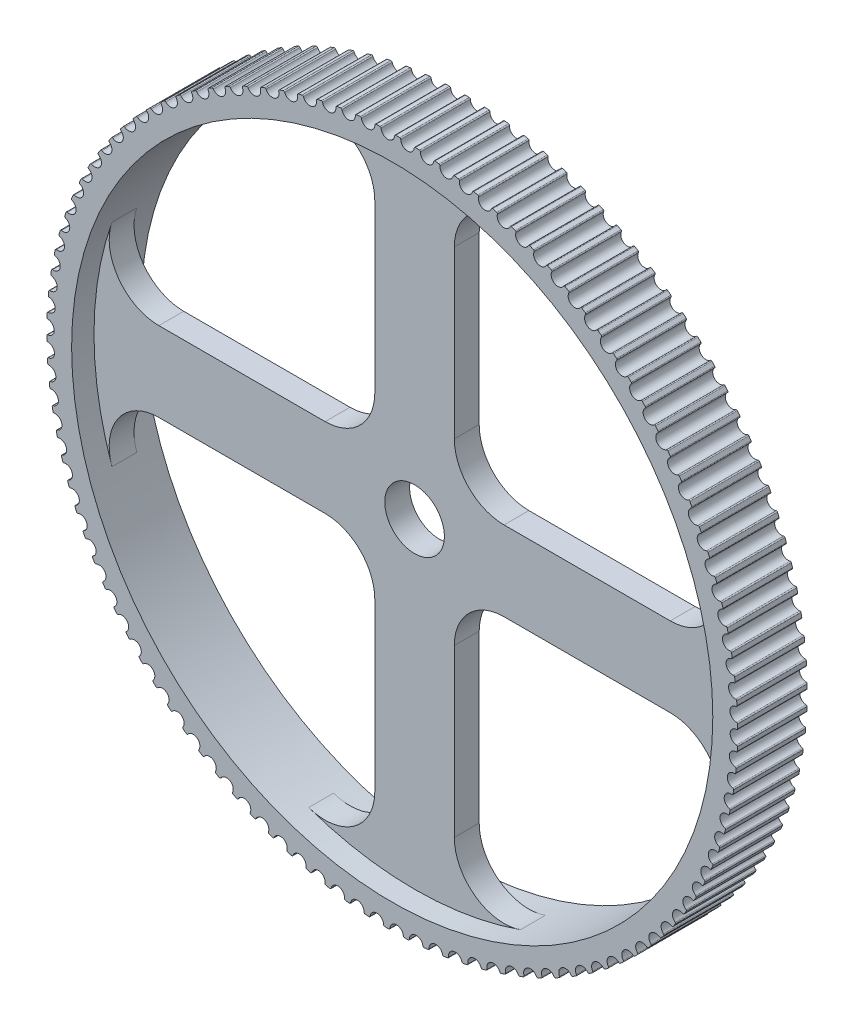
from build123d import *

# Parameters (mm, degrees)
BOSS_EXTRUDE1_DEPTH = 3.5
SKETCH4_R           = 32.25
CUT_EXTRUDE2_DEPTH  = 3.5
SKETCH6_R           = 3
BOSS_EXTRUDE2_DEPTH = 1.25
FILLET1_R           = 5
FILLET2_R           = 5


with BuildPart() as part:
    # Sketch2 → Boss-Extrude1 (new body, symmetric)
    with BuildSketch(Plane.XY):
        with BuildLine():
            ThreePointArc((-3.211333328, 34.601298216), (-3.132582306, 34.577768977), (-3.092122191, 34.506226488))
            ThreePointArc((-3.092122191, 34.506226488), (-2.370608918, 33.917255392), (-1.738041502, 34.600868455))
            ThreePointArc((-1.738041502, 34.600868455), (-1.707926922, 34.677343683), (-1.633214692, 34.711599067))
            ThreePointArc((-1.633214692, 34.711599067), (-1.432005901, 34.720481839), (-1.230749008, 34.728198296))
            ThreePointArc((-1.230749008, 34.728198296), (-1.153469677, 34.700211628), (-1.117159824, 34.626475997))
            ThreePointArc((-1.117159824, 34.626475997), (-0.430446923, 33.997275118), (0.240115498, 34.643660757))
            ThreePointArc((0.240115498, 34.643660757), (0.274546844, 34.718292057), (0.351092826, 34.748226341))
            ThreePointArc((0.351092826, 34.748226341), (0.552480572, 34.745607855), (0.75384976, 34.741822211))
            ThreePointArc((0.75384976, 34.741822211), (0.829405331, 34.709469401), (0.861446487, 34.63378114))
            ThreePointArc((0.861446487, 34.63378114), (1.5111191, 33.966402798), (2.217489291, 34.573452638))
            ThreePointArc((2.217489291, 34.573452638), (2.256125096, 34.645996578), (2.334255151, 34.671512123))
            ThreePointArc((2.334255151, 34.671512123), (2.535164969, 34.657400921), (2.735989626, 34.642125523))
            ThreePointArc((2.735989626, 34.642125523), (2.809574991, 34.6055121), (2.837242938, 34.528118086))
            ThreePointArc((2.837242938, 34.528118086), (3.447756167, 33.824739133), (4.187630095, 34.390473103))
            ThreePointArc((4.187630095, 34.390473103), (4.230344336, 34.460693059), (4.309803622, 34.481706639))
            ThreePointArc((4.309803622, 34.481706639), (4.509580184, 34.456148748), (4.709205264, 34.429433422))
            ThreePointArc((4.709205264, 34.429433422), (4.780580401, 34.388678811), (4.803784892, 34.309831489))
            ThreePointArc((4.803784892, 34.309831489), (5.373147369, 33.572746199), (6.14411172, 34.095318993))
            ThreePointArc((6.14411172, 34.095318993), (6.190765072, 34.162985922), (6.271294408, 34.179428995))
            ThreePointArc((6.271294408, 34.179428995), (6.469286087, 34.14250778), (6.667060452, 34.104439666))
            ThreePointArc((6.667060452, 34.104439666), (6.735992552, 34.059676799), (6.754657899, 33.979633352))
            ThreePointArc((6.754657899, 33.979633352), (7.281012482, 33.211245945), (8.080552529, 33.68895304))
            ThreePointArc((8.080552529, 33.68895304), (8.13099282, 33.753846226), (8.212329536, 33.765665158))
            ThreePointArc((8.212329536, 33.765665158), (8.407890523, 33.717501049), (8.603169075, 33.668204316))
            ThreePointArc((8.603169075, 33.668204316), (8.669433295, 33.619579201), (8.683498616, 33.538600714))
            ThreePointArc((8.683498616, 33.538600714), (9.165128446, 32.74141751), (9.990636256, 33.172700723))
            ThreePointArc((9.990636256, 33.172700723), (10.044698959, 33.2346085), (10.126577752, 33.24176474))
            ThreePointArc((10.126577752, 33.24176474), (10.319070167, 33.182514837), (10.511215949, 33.122150282))
            ThreePointArc((10.511215949, 33.122150282), (10.574596148, 33.069821524), (10.584015565, 32.988172132))
            ThreePointArc((10.584015565, 32.988172132), (11.019349666, 32.164793376), (11.868132604, 32.548245952))
            ThreePointArc((11.868132604, 32.548245952), (11.925641377, 32.606966388), (12.007795176, 32.609436594))
            ThreePointArc((12.007795176, 32.609436594), (12.196591149, 32.539294158), (12.384977421, 32.468058678))
            ThreePointArc((12.384977421, 32.468058678), (12.445266867, 32.412196962), (12.450009655, 32.330142989))
            ThreePointArc((12.450009655, 32.330142989), (12.837628057, 31.483254372), (13.70691757, 31.817625568))
            ThreePointArc((13.70691757, 31.817625568), (13.767684832, 31.87296713), (13.849845668, 31.870743245))
            ThreePointArc((13.849845668, 31.870743245), (14.034329387, 31.789937066), (14.21834167, 31.708063015))
            ThreePointArc((14.21834167, 31.708063015), (14.275343712, 31.648850551), (14.275394401, 31.566659639))
            ThreePointArc((14.275394401, 31.566659639), (14.614032774, 30.699023536), (15.50099342, 30.983222703))
            ThreePointArc((15.50099342, 30.983222703), (15.564820961, 31.035004878), (15.646720842, 31.028094155))
            ThreePointArc((15.646720842, 31.028094155), (15.826290558, 30.936887807), (16.005328645, 30.844642241))
            ThreePointArc((16.005328645, 30.844642241), (16.058857353, 30.782272168), (16.054215778, 30.700212407))
            ThreePointArc((16.054215778, 30.700212407), (16.342769554, 29.814658866), (17.244508252, 30.047759005))
            ThreePointArc((17.244508252, 30.047759005), (17.31118788, 30.09581289), (17.392559666, 30.084237871))
            ThreePointArc((17.392559666, 30.084237871), (17.56662966, 29.982928849), (17.740109564, 29.880612655))
            ThreePointArc((17.740109564, 29.880612655), (17.78999034, 29.815288411), (17.78067164, 29.733627463))
            ThreePointArc((17.78067164, 29.733627463), (18.018199616, 28.833044976), (18.931775082, 29.014285763))
            ThreePointArc((18.931775082, 29.014285763), (19.001089301, 29.058454616), (19.081667574, 29.042253056))
            ThreePointArc((19.081667574, 29.042253056), (19.249670067, 28.93117181), (19.417025934, 28.819118722))
            ThreePointArc((19.417025934, 28.819118722), (19.463096075, 28.75105338), (19.449130647, 28.670057606))
            ThreePointArc((19.449130647, 28.670057606), (19.634858056, 27.757383686), (20.557290396, 27.886173951))
            ThreePointArc((20.557290396, 27.886173951), (20.629013119, 27.926313703), (20.708535049, 27.905538449))
            ThreePointArc((20.708535049, 27.905538449), (20.869922051, 27.785047302), (21.030608, 27.663622813))
            ThreePointArc((21.030608, 27.663622813), (21.072717237, 27.59303839), (21.054150632, 27.512971981))
            ThreePointArc((21.054150632, 27.512971981), (21.187471671, 26.59118358), (22.115752103, 26.667103236))
            ThreePointArc((22.115752103, 26.667103236), (22.189649383, 26.70308296), (22.267855587, 26.677801775))
            ThreePointArc((22.267855587, 26.677801775), (22.422100687, 26.548293745), (22.575592595, 26.417893917))
            ThreePointArc((22.575592595, 26.417893917), (22.613603575, 26.345020643), (22.590496355, 26.26614476))
            ThreePointArc((22.590496355, 26.26614476), (22.670976156, 25.338248561), (23.602076822, 25.361049973))
            ThreePointArc((23.602076822, 25.361049973), (23.677907624, 25.39275231), (23.754543009, 25.363047657))
            ThreePointArc((23.754543009, 25.363047657), (23.901143092, 25.224945172), (24.046940299, 25.085995341))
            ThreePointArc((24.046940299, 25.085995341), (24.080729038, 25.011070915), (24.053156573, 24.933642834))
            ThreePointArc((24.053156573, 24.933642834), (24.08053263, 24.002665441), (25.011416473, 23.972274237))
            ThreePointArc((25.011416473, 23.972274237), (25.088933451, 23.99959578), (25.163748048, 23.965564549))
            ThreePointArc((25.163748048, 23.965564549), (25.302224935, 23.81931807), (25.439851882, 23.672271464))
            ThreePointArc((25.439851882, 23.672271464), (25.469308169, 23.595540272), (25.437360394, 23.519812547))
            ThreePointArc((25.437360394, 23.519812547), (25.411543411, 22.588790615), (26.339174082, 22.505305925))
            ThreePointArc((26.339174082, 22.505305925), (26.418124392, 22.528157557), (26.490874172, 22.489910751))
            ThreePointArc((26.490874172, 22.489910751), (26.62077618, 22.335997304), (26.749783955, 22.181333557))
            ThreePointArc((26.749783955, 22.181333557), (26.77481171, 22.103045881), (26.738592833, 22.029265521))
            ThreePointArc((26.738592833, 22.029265521), (26.65966702, 21.10123585), (27.58101878, 20.964929982))
            ThreePointArc((27.58101878, 20.964929982), (27.661144903, 20.983237166), (27.731592571, 20.940899539))
            ThreePointArc((27.731592571, 20.940899539), (27.852495986, 20.779821157), (27.972463794, 20.61804475))
            ThreePointArc((27.972463794, 20.61804475), (27.99298138, 20.538455949), (27.95260954, 20.466863609))
            ThreePointArc((27.95260954, 20.466863609), (27.820832336, 19.544853239), (28.732899927, 19.356170796))
            ThreePointArc((28.732899927, 19.356170796), (28.813940508, 19.369873818), (28.881856278, 19.323583465))
            ThreePointArc((28.881856278, 19.323583465), (28.99336674, 19.155865553), (29.103903269, 18.987504167))
            ThreePointArc((29.103903269, 18.987504167), (29.119843764, 18.906873842), (29.075450644, 18.837703042))
            ThreePointArc((29.075450644, 18.837703042), (28.89125188, 17.924719379), (29.791060327, 17.684275803))
            ThreePointArc((29.791060327, 17.684275803), (29.872751028, 17.693329967), (29.937913374, 17.643237878))
            ThreePointArc((29.937913374, 17.643237878), (30.039667157, 17.469427497), (30.140411862, 17.295030292))
            ThreePointArc((30.140411862, 17.295030292), (30.15172327, 17.213621443), (30.103453672, 17.147097804))
            ThreePointArc((30.103453672, 17.147097804), (29.867434165, 16.24611881), (30.75204848, 15.954698379))
            ThreePointArc((30.75204848, 15.954698379), (30.834122844, 15.959074151), (30.896319219, 15.905343716))
            ThreePointArc((30.896319219, 15.905343716), (30.987984424, 15.7260078), (31.078608696, 15.546143623))
            ThreePointArc((31.078608696, 15.546143623), (31.085254121, 15.464221788), (31.033265491, 15.400562296))
            ThreePointArc((31.033265491, 15.400562296), (30.746195088, 14.514526779), (31.612729843, 14.173080045))
            ThreePointArc((31.612729843, 14.173080045), (31.69492016, 14.172763152), (31.753947692, 14.115569629))
            ThreePointArc((31.753947692, 14.115569629), (31.835225327, 13.931293134), (31.915433568, 13.746548664))
            ThreePointArc((31.915433568, 13.746548664), (31.917391335, 13.664381057), (31.861853248, 13.603793356))
            ThreePointArc((31.861853248, 13.603793356), (31.524668313, 12.735591378), (32.370297052, 12.345232069))
            ThreePointArc((32.370297052, 12.345232069), (32.452335234, 12.340223546), (32.508001388, 12.279753488))
            ThreePointArc((32.508001388, 12.279753488), (32.578626342, 12.091137485), (32.648156929, 11.902115321))
            ThreePointArc((32.648156929, 11.902115321), (32.645420653, 11.819969954), (32.586514263, 11.762651669))
            ThreePointArc((32.586514263, 11.762651669), (32.200314623, 10.915115125), (33.02227908, 10.477116513))
            ThreePointArc((33.02227908, 10.477116513), (33.103897536, 10.467432696), (33.156020741, 10.403883344))
            ThreePointArc((33.156020741, 10.403883344), (33.215762649, 10.211543059), (33.274388789, 10.018859752))
            ThreePointArc((33.274388789, 10.018859752), (33.266967394, 9.937004566), (33.204884841, 9.883142657))
            ThreePointArc((33.204884841, 9.883142657), (32.770930199, 9.059036036), (33.566549298, 8.57482678))
            ThreePointArc((33.566549298, 8.57482678), (33.647481805, 8.560499256), (33.695892045, 8.494077894))
            ThreePointArc((33.695892045, 8.494077894), (33.744556042, 8.298640702), (33.792086508, 8.102924745))
            ThreePointArc((33.792086508, 8.102924745), (33.780004201, 8.021626735), (33.714947986, 7.971396888))
            ThreePointArc((33.714947986, 7.971396888), (33.234653812, 7.173408254), (34.001332409, 6.644567744))
            ThreePointArc((34.001332409, 6.644567744), (34.081314982, 6.625643246), (34.125854354, 6.556566528))
            ThreePointArc((34.125854354, 6.556566528), (34.163281708, 6.358669904), (34.199561465, 6.160559682))
            ThreePointArc((34.199561465, 6.160559682), (34.182857657, 6.080084025), (34.115039979, 6.033650079))
            ThreePointArc((34.115039979, 6.033650079), (33.589972893, 5.264382305), (34.32521024, 4.69263551))
            ThreePointArc((34.32521024, 4.69263551), (34.403981993, 4.669175766), (34.444505218, 4.597669005))
            ThreePointArc((34.444505218, 4.597669005), (34.470573849, 4.397958446), (34.495484561, 4.198100153))
            ThreePointArc((34.495484561, 4.198100153), (34.474213735, 4.118709344), (34.403855803, 4.076222758))
            ThreePointArc((34.403855803, 4.076222758), (33.835728464, 3.338185035), (34.537126371, 2.725396874))
            ThreePointArc((34.537126371, 2.725396874), (34.614430366, 2.697478404), (34.650805266, 2.623774841))
            ThreePointArc((34.650805266, 2.623774841), (34.665430144, 2.422901762), (34.678890556, 2.221947294))
            ThreePointArc((34.678890556, 2.221947294), (34.653122094, 2.143900289), (34.5804534, 2.105499646))
            ThreePointArc((34.5804534, 2.105499646), (33.971118921, 1.401099299), (34.636389574, 0.74926856))
            ThreePointArc((34.636389574, 0.74926856), (34.711973662, 0.716982429), (34.744081589, 0.641322469))
            ThreePointArc((34.744081589, 0.641322469), (34.74721501, 0.439942076), (34.749181219, 0.238546905))
            ThreePointArc((34.749181219, 0.238546905), (34.718999171, 0.162098278), (34.644256745, 0.127908831))
            ThreePointArc((34.644256745, 0.127908831), (33.99570265, -0.540556531), (34.622676073, -1.229303713))
            ThreePointArc((34.622676073, -1.229303713), (34.696293715, -1.265852194), (34.72402994, -1.343221764))
            ThreePointArc((34.72402994, -1.343221764), (34.715661684, -1.544452609), (34.706127275, -1.745631574))
            ThreePointArc((34.706127275, -1.745631574), (34.67163009, -1.820232465), (34.595057726, -1.850099196))
            ThreePointArc((34.595057726, -1.850099196), (33.909399462, -2.480449178), (34.496030599, -3.203866252))
            ThreePointArc((34.496030599, -3.203866252), (34.567441669, -3.24455787), (34.590715723, -3.323384687))
            ThreePointArc((34.590715723, -3.323384687), (34.570873084, -3.523809611), (34.549869157, -3.724116166))
            ThreePointArc((34.549869157, -3.724116166), (34.511169358, -3.796625987), (34.433016819, -3.822072584))
            ThreePointArc((34.433016819, -3.822072584), (33.712490862, -4.412251116), (34.256866244, -5.167978446))
            ThreePointArc((34.256866244, -5.167978446), (34.325837814, -5.212680473), (34.344573781, -5.292707419))
            ThreePointArc((34.344573781, -5.292707419), (34.313321483, -5.491672679), (34.280916548, -5.690453466))
            ThreePointArc((34.280916548, -5.690453466), (34.238140364, -5.760635705), (34.158662568, -5.781579165))
            ThreePointArc((34.158662568, -5.781579165), (33.405619123, -6.329661207), (33.905963111, -7.115233768))
            ThreePointArc((33.905963111, -7.115233768), (33.97227021, -7.163800395), (33.986406977, -7.24476644))
            ThreePointArc((33.986406977, -7.24476644), (33.943846959, -7.441623052), (33.900146714, -7.638229688))
            ThreePointArc((33.900146714, -7.638229688), (33.853433673, -7.705855426), (33.77288986, -7.722227437))
            ThreePointArc((33.77288986, -7.722227437), (32.989785199, -8.226425259), (33.444465774, -9.039280676))
            ThreePointArc((33.444465774, -9.039280676), (33.507892122, -9.09155349), (33.517383579, -9.173194539))
            ThreePointArc((33.517383579, -9.173194539), (33.463654661, -9.367300397), (33.408801648, -9.561091593))
            ThreePointArc((33.408801648, -9.561091593), (33.358304118, -9.625940249), (33.276957005, -9.637687408))
            ThreePointArc((33.276957005, -9.637687408), (32.466345452, -10.096356422), (32.873879542, -10.93384333))
            ThreePointArc((32.873879542, -10.93384333), (32.934218255, -10.989651827), (32.939033441, -11.071701583))
            ThreePointArc((32.939033441, -11.071701583), (32.874310877, -11.262423555), (32.808484015, -11.452767205))
            ThreePointArc((32.808484015, -11.452767205), (32.754366709, -11.514627255), (32.672481633, -11.521711246))
            ThreePointArc((32.672481633, -11.521711246), (31.837007234, -11.933355369), (32.196065547, -12.792742059))
            ThreePointArc((32.196065547, -12.792742059), (32.253119813, -12.851904204), (32.253243023, -12.934095039))
            ThreePointArc((32.253243023, -12.934095039), (32.177737925, -13.120811029), (32.101151926, -13.307086271))
            ThreePointArc((32.101151926, -13.307086271), (32.043591363, -13.365755941), (31.961435416, -13.368153657))
            ThreePointArc((31.961435416, -13.368153657), (31.103823316, -13.731430191), (31.413234678, -14.609913523))
            ThreePointArc((31.413234678, -14.609913523), (31.466818398, -14.67223634), (31.462249231, -14.754300165))
            ThreePointArc((31.462249231, -14.754300165), (31.376207879, -14.936401144), (31.289112552, -15.118000387))
            ThreePointArc((31.289112552, -15.118000387), (31.228296483, -15.173288309), (31.146137641, -15.170991929))
            ThreePointArc((31.146137641, -15.170991929), (30.269185192, -15.484715942), (30.527940367, -16.379430485))
            ThreePointArc((30.527940367, -16.379430485), (30.577878762, -16.444710691), (30.56863212, -16.52637983))
            ThreePointArc((30.56863212, -16.52637983), (30.472335165, -16.703271823), (30.375014597, -16.879602728))
            ThreePointArc((30.375014597, -16.879602728), (30.31114139, -16.931328564), (30.229247639, -16.924345579))
            ThreePointArc((30.229247639, -16.924345579), (29.335815277, -17.187493768), (29.54307026, -18.09552115))
            ThreePointArc((29.54307026, -18.09552115), (29.589200441, -18.163545815), (29.575306486, -18.24455388))
            ThreePointArc((29.575306486, -18.24455388), (29.469068027, -18.415659902), (29.361839657, -18.586147313))
            ThreePointArc((29.361839657, -18.586147313), (29.295117655, -18.634142344), (29.213756114, -18.622495531))
            ThreePointArc((29.213756114, -18.622495531), (28.30675803, -18.834209562), (28.461836798, -19.752587986))
            ThreePointArc((28.461836798, -19.752587986), (28.504008299, -19.823135227), (28.485512349, -19.903217987))
            ThreePointArc((28.485512349, -19.903217987), (28.369678915, -20.067979925), (28.252892499, -20.232067749))
            ThreePointArc((28.252892499, -20.232067749), (28.183539334, -20.276175426), (28.102975388, -20.259902774))
            ThreePointArc((28.102975388, -20.259902774), (27.185370022, -20.419492079), (27.287766741, -21.345225986))
            ThreePointArc((27.287766741, -21.345225986), (27.325842006, -21.418065692), (27.302804391, -21.496961933))
            ThreePointArc((27.302804391, -21.496961933), (27.177753806, -21.654842369), (27.051790279, -21.811995386))
            ThreePointArc((27.051790279, -21.811995386), (26.980032167, -21.852071837), (26.900528599, -21.831226424))
            ThreePointArc((26.900528599, -21.831226424), (25.975308988, -21.938170457), (26.02468966, -22.868240295))
            ThreePointArc((26.02468966, -22.868240295), (26.058544496, -22.943134878), (26.031040361, -23.020587258))
            ThreePointArc((26.031040361, -23.020587258), (25.897180514, -23.171071219), (25.762450741, -23.320776827))
            ThreePointArc((25.762450741, -23.320776827), (25.688521742, -23.356691333), (25.610337876, -23.331341152))
            ThreePointArc((25.610337876, -23.331341152), (24.680521894, -23.385291083), (24.676725451, -24.316663157))
            ThreePointArc((24.676725451, -24.316663157), (24.706249431, -24.393368328), (24.674368488, -24.469124213))
            ThreePointArc((24.674368488, -24.469124213), (24.532136002, -24.61172085), (24.389079444, -24.753490741))
            ThreePointArc((24.389079444, -24.753490741), (24.313220699, -24.785126155), (24.236611554, -24.755353895))
            ThreePointArc((24.236611554, -24.755353895), (23.305232069, -24.75613375), (23.248270892, -25.685770119))
            ThreePointArc((23.248270892, -25.685770119), (23.273367715, -25.76403568), (23.237213953, -25.83784797))
            ThreePointArc((23.237213953, -25.83784797), (23.087072761, -25.972092163), (22.936156039, -26.105463914))
            ThreePointArc((22.936156039, -26.105463914), (22.858614984, -26.132717049), (22.783830443, -26.098619818))
            ThreePointArc((22.783830443, -26.098619818), (21.85392542, -26.046227054), (21.743985306, -26.971095437))
            ThreePointArc((21.743985306, -26.971095437), (21.764573111, -27.050666103), (21.724264456, -27.122294037))
            ThreePointArc((21.724264456, -27.122294037), (21.566704287, -27.24774791), (21.40841966, -27.372286489))
            ThreePointArc((21.40841966, -27.372286489), (21.329449217, -27.39506845), (21.256733213, -27.356757468))
            ThreePointArc((21.256733213, -27.356757468), (20.331335809, -27.251362979), (20.16877536, -28.168446648))
            ThreePointArc((20.16877536, -28.168446648), (20.184786993, -28.249062876), (20.140454924, -28.318272819))
            ThreePointArc((20.140454924, -28.318272819), (19.975989707, -28.434527167), (19.810853466, -28.549826356))
            ThreePointArc((19.810853466, -28.549826356), (19.730711221, -28.568062833), (19.660300937, -28.525663062))
            ThreePointArc((19.660300937, -28.525663062), (18.742429606, -28.367610623), (18.527779061, -29.273918241))
            ThreePointArc((18.527779061, -29.273918241), (18.539162295, -29.355317077), (18.490951414, -29.421883281))
            ThreePointArc((18.490951414, -29.421883281), (18.320117601, -29.528558907), (18.148668386, -29.634242622))
            ThreePointArc((18.148668386, -29.634242622), (18.067615746, -29.647874132), (17.999740847, -29.601523872))
            ThreePointArc((17.999740847, -29.601523872), (17.092389494, -29.391329017), (16.826348997, -30.283904397))
            ThreePointArc((16.826348997, -30.283904397), (16.833066704, -30.365820336), (16.781134264, -30.429525675))
            ThreePointArc((16.781134264, -30.429525675), (16.604489078, -30.526274624), (16.427286122, -30.621998149))
            ThreePointArc((16.427286122, -30.621998149), (16.345587463, -30.630980229), (16.280469342, -30.580830663))
            ThreePointArc((16.280469342, -30.580830663), (15.38659756, -30.319179005), (15.07003488, -31.195110751))
            ThreePointArc((15.07003488, -31.195110751), (15.072065148, -31.2772766), (15.016580542, -31.337913281))
            ThreePointArc((15.016580542, -31.337913281), (14.834700164, -31.42441998), (14.652321465, -31.509871083))
            ThreePointArc((14.652321465, -31.509871083), (14.570243272, -31.514174435), (14.508094331, -31.460389142))
            ThreePointArc((14.508094331, -31.460389142), (13.630617742, -31.148134133), (13.264565442, -32.004565139))
            ThreePointArc((13.264565442, -32.004565139), (13.261901648, -32.086712889), (13.203045856, -32.144083128))
            ThreePointArc((13.203045856, -32.144083128), (13.016523541, -32.220065408), (12.829563981, -32.294965367))
            ThreePointArc((12.829563981, -32.294965367), (12.747373976, -32.294575954), (12.688396932, -32.23733037))
            ThreePointArc((12.688396932, -32.23733037), (11.830177683, -31.875490522), (11.415829748, -32.709627287))
            ThreePointArc((11.415829748, -32.709627287), (11.408480581, -32.791488989), (11.346445578, -32.845405657))
            ThreePointArc((11.346445578, -32.845405657), (11.155889724, -32.910615681), (10.964959126, -32.974720186))
            ThreePointArc((10.964959126, -32.974720186), (10.882925395, -32.969639279), (10.827312619, -32.909120127))
            ThreePointArc((10.827312619, -32.909120127), (9.991150043, -32.498875685), (9.529857991, -33.307997429))
            ThreePointArc((9.529857991, -33.307997429), (9.517847422, -33.389306069), (9.452835553, -33.439593299))
            ThreePointArc((9.452835553, -33.439593299), (9.258867713, -33.493818365), (9.064588853, -33.546918322))
            ThreePointArc((9.064588853, -33.546918322), (8.982978974, -33.537162493), (8.930911862, -33.473567174))
            ThreePointArc((8.930911862, -33.473567174), (8.119533349, -33.016256272), (7.612801817, -33.797723808))
            ThreePointArc((7.612801817, -33.797723808), (7.596169023, -33.878214172), (7.528392344, -33.924707939))
            ThreePointArc((7.528392344, -33.924707939), (7.3316452, -33.967771176), (7.134651776, -34.009693384))
            ThreePointArc((7.134651776, -34.009693384), (7.053731942, -33.995294454), (7.005380328, -33.928830403))
            ThreePointArc((7.005380328, -33.928830403), (6.221432424, -33.425944693), (5.670914266, -34.177209036))
            ThreePointArc((5.670914266, -34.177209036), (5.6497135, -34.256618582), (5.579393083, -34.299167232))
            ThreePointArc((5.579393083, -34.299167232), (5.380508385, -34.330928177), (5.181442947, -34.361535894))
            ThreePointArc((5.181442947, -34.361535894), (5.101477103, -34.34254083), (5.056998699, -34.27342484))
            ThreePointArc((5.056998699, -34.27342484), (4.30303848, -33.72660463), (3.710529372, -34.445215311))
            ThreePointArc((3.710529372, -34.445215311), (3.684829785, -34.523285023), (3.612195002, -34.561749771))
            ThreePointArc((3.612195002, -34.561749771), (3.411821469, -34.582104827), (3.211333328, -34.601298216))
            ThreePointArc((3.211333328, -34.601298216), (3.132582306, -34.577768977), (3.092122191, -34.506226488))
            ThreePointArc((3.092122191, -34.506226488), (2.370608918, -33.917255392), (1.738041502, -34.600868455))
            ThreePointArc((1.738041502, -34.600868455), (1.707926922, -34.677343683), (1.633214692, -34.711599067))
            ThreePointArc((1.633214692, -34.711599067), (1.432005901, -34.720481839), (1.230749008, -34.728198296))
            ThreePointArc((1.230749008, -34.728198296), (1.153469677, -34.700211628), (1.117159824, -34.626475997))
            ThreePointArc((1.117159824, -34.626475997), (0.430446923, -33.997275118), (-0.240115498, -34.643660757))
            ThreePointArc((-0.240115498, -34.643660757), (-0.274546844, -34.718292057), (-0.351092826, -34.748226341))
            ThreePointArc((-0.351092826, -34.748226341), (-0.552480572, -34.745607855), (-0.75384976, -34.741822211))
            ThreePointArc((-0.75384976, -34.741822211), (-0.829405331, -34.709469401), (-0.861446487, -34.63378114))
            ThreePointArc((-0.861446487, -34.63378114), (-1.5111191, -33.966402798), (-2.217489291, -34.573452638))
            ThreePointArc((-2.217489291, -34.573452638), (-2.256125096, -34.645996578), (-2.334255151, -34.671512123))
            ThreePointArc((-2.334255151, -34.671512123), (-2.535164969, -34.657400921), (-2.735989626, -34.642125523))
            ThreePointArc((-2.735989626, -34.642125523), (-2.809574991, -34.6055121), (-2.837242938, -34.528118086))
            ThreePointArc((-2.837242938, -34.528118086), (-3.447756167, -33.824739133), (-4.187630095, -34.390473103))
            ThreePointArc((-4.187630095, -34.390473103), (-4.230344336, -34.460693059), (-4.309803622, -34.481706639))
            ThreePointArc((-4.309803622, -34.481706639), (-4.509580184, -34.456148748), (-4.709205264, -34.429433422))
            ThreePointArc((-4.709205264, -34.429433422), (-4.780580401, -34.388678811), (-4.803784892, -34.309831489))
            ThreePointArc((-4.803784892, -34.309831489), (-5.373147369, -33.572746199), (-6.14411172, -34.095318993))
            ThreePointArc((-6.14411172, -34.095318993), (-6.190765072, -34.162985922), (-6.271294408, -34.179428995))
            ThreePointArc((-6.271294408, -34.179428995), (-6.469286087, -34.14250778), (-6.667060452, -34.104439666))
            ThreePointArc((-6.667060452, -34.104439666), (-6.735992552, -34.059676799), (-6.754657899, -33.979633352))
            ThreePointArc((-6.754657899, -33.979633352), (-7.281012482, -33.211245945), (-8.080552529, -33.68895304))
            ThreePointArc((-8.080552529, -33.68895304), (-8.13099282, -33.753846226), (-8.212329536, -33.765665158))
            ThreePointArc((-8.212329536, -33.765665158), (-8.407890523, -33.717501049), (-8.603169075, -33.668204316))
            ThreePointArc((-8.603169075, -33.668204316), (-8.669433295, -33.619579201), (-8.683498616, -33.538600714))
            ThreePointArc((-8.683498616, -33.538600714), (-9.165128446, -32.74141751), (-9.990636256, -33.172700723))
            ThreePointArc((-9.990636256, -33.172700723), (-10.044698959, -33.2346085), (-10.126577752, -33.24176474))
            ThreePointArc((-10.126577752, -33.24176474), (-10.319070167, -33.182514837), (-10.511215949, -33.122150282))
            ThreePointArc((-10.511215949, -33.122150282), (-10.574596148, -33.069821524), (-10.584015565, -32.988172132))
            ThreePointArc((-10.584015565, -32.988172132), (-11.019349666, -32.164793376), (-11.868132604, -32.548245952))
            ThreePointArc((-11.868132604, -32.548245952), (-11.925641377, -32.606966388), (-12.007795176, -32.609436594))
            ThreePointArc((-12.007795176, -32.609436594), (-12.196591149, -32.539294158), (-12.384977421, -32.468058678))
            ThreePointArc((-12.384977421, -32.468058678), (-12.445266867, -32.412196962), (-12.450009655, -32.330142989))
            ThreePointArc((-12.450009655, -32.330142989), (-12.837628057, -31.483254372), (-13.70691757, -31.817625568))
            ThreePointArc((-13.70691757, -31.817625568), (-13.767684832, -31.87296713), (-13.849845668, -31.870743245))
            ThreePointArc((-13.849845668, -31.870743245), (-14.034329387, -31.789937066), (-14.21834167, -31.708063015))
            ThreePointArc((-14.21834167, -31.708063015), (-14.275343712, -31.648850551), (-14.275394401, -31.566659639))
            ThreePointArc((-14.275394401, -31.566659639), (-14.614032774, -30.699023536), (-15.50099342, -30.983222703))
            ThreePointArc((-15.50099342, -30.983222703), (-15.564820961, -31.035004878), (-15.646720842, -31.028094155))
            ThreePointArc((-15.646720842, -31.028094155), (-15.826290558, -30.936887807), (-16.005328645, -30.844642241))
            ThreePointArc((-16.005328645, -30.844642241), (-16.058857353, -30.782272168), (-16.054215778, -30.700212407))
            ThreePointArc((-16.054215778, -30.700212407), (-16.342769554, -29.814658866), (-17.244508252, -30.047759005))
            ThreePointArc((-17.244508252, -30.047759005), (-17.31118788, -30.09581289), (-17.392559666, -30.084237871))
            ThreePointArc((-17.392559666, -30.084237871), (-17.56662966, -29.982928849), (-17.740109564, -29.880612655))
            ThreePointArc((-17.740109564, -29.880612655), (-17.78999034, -29.815288411), (-17.78067164, -29.733627463))
            ThreePointArc((-17.78067164, -29.733627463), (-18.018199616, -28.833044976), (-18.931775082, -29.014285763))
            ThreePointArc((-18.931775082, -29.014285763), (-19.001089301, -29.058454616), (-19.081667574, -29.042253056))
            ThreePointArc((-19.081667574, -29.042253056), (-19.249670067, -28.93117181), (-19.417025934, -28.819118722))
            ThreePointArc((-19.417025934, -28.819118722), (-19.463096075, -28.75105338), (-19.449130647, -28.670057606))
            ThreePointArc((-19.449130647, -28.670057606), (-19.634858056, -27.757383686), (-20.557290396, -27.886173951))
            ThreePointArc((-20.557290396, -27.886173951), (-20.629013119, -27.926313703), (-20.708535049, -27.905538449))
            ThreePointArc((-20.708535049, -27.905538449), (-20.869922051, -27.785047302), (-21.030608, -27.663622813))
            ThreePointArc((-21.030608, -27.663622813), (-21.072717237, -27.59303839), (-21.054150632, -27.512971981))
            ThreePointArc((-21.054150632, -27.512971981), (-21.187471671, -26.59118358), (-22.115752103, -26.667103236))
            ThreePointArc((-22.115752103, -26.667103236), (-22.189649383, -26.70308296), (-22.267855587, -26.677801775))
            ThreePointArc((-22.267855587, -26.677801775), (-22.422100687, -26.548293745), (-22.575592595, -26.417893917))
            ThreePointArc((-22.575592595, -26.417893917), (-22.613603575, -26.345020643), (-22.590496355, -26.26614476))
            ThreePointArc((-22.590496355, -26.26614476), (-22.670976156, -25.338248561), (-23.602076822, -25.361049973))
            ThreePointArc((-23.602076822, -25.361049973), (-23.677907624, -25.39275231), (-23.754543009, -25.363047657))
            ThreePointArc((-23.754543009, -25.363047657), (-23.901143092, -25.224945172), (-24.046940299, -25.085995341))
            ThreePointArc((-24.046940299, -25.085995341), (-24.080729038, -25.011070915), (-24.053156573, -24.933642834))
            ThreePointArc((-24.053156573, -24.933642834), (-24.08053263, -24.002665441), (-25.011416473, -23.972274237))
            ThreePointArc((-25.011416473, -23.972274237), (-25.088933451, -23.99959578), (-25.163748048, -23.965564549))
            ThreePointArc((-25.163748048, -23.965564549), (-25.302224935, -23.81931807), (-25.439851882, -23.672271464))
            ThreePointArc((-25.439851882, -23.672271464), (-25.469308169, -23.595540272), (-25.437360394, -23.519812547))
            ThreePointArc((-25.437360394, -23.519812547), (-25.411543411, -22.588790615), (-26.339174082, -22.505305925))
            ThreePointArc((-26.339174082, -22.505305925), (-26.418124392, -22.528157557), (-26.490874172, -22.489910751))
            ThreePointArc((-26.490874172, -22.489910751), (-26.62077618, -22.335997304), (-26.749783955, -22.181333557))
            ThreePointArc((-26.749783955, -22.181333557), (-26.77481171, -22.103045881), (-26.738592833, -22.029265521))
            ThreePointArc((-26.738592833, -22.029265521), (-26.65966702, -21.10123585), (-27.58101878, -20.964929982))
            ThreePointArc((-27.58101878, -20.964929982), (-27.661144903, -20.983237166), (-27.731592571, -20.940899539))
            ThreePointArc((-27.731592571, -20.940899539), (-27.852495986, -20.779821157), (-27.972463794, -20.61804475))
            ThreePointArc((-27.972463794, -20.61804475), (-27.99298138, -20.538455949), (-27.95260954, -20.466863609))
            ThreePointArc((-27.95260954, -20.466863609), (-27.820832336, -19.544853239), (-28.732899927, -19.356170796))
            ThreePointArc((-28.732899927, -19.356170796), (-28.813940508, -19.369873818), (-28.881856278, -19.323583465))
            ThreePointArc((-28.881856278, -19.323583465), (-28.99336674, -19.155865553), (-29.103903269, -18.987504167))
            ThreePointArc((-29.103903269, -18.987504167), (-29.119843764, -18.906873842), (-29.075450644, -18.837703042))
            ThreePointArc((-29.075450644, -18.837703042), (-28.89125188, -17.924719379), (-29.791060327, -17.684275803))
            ThreePointArc((-29.791060327, -17.684275803), (-29.872751028, -17.693329967), (-29.937913374, -17.643237878))
            ThreePointArc((-29.937913374, -17.643237878), (-30.039667157, -17.469427497), (-30.140411862, -17.295030292))
            ThreePointArc((-30.140411862, -17.295030292), (-30.15172327, -17.213621443), (-30.103453672, -17.147097804))
            ThreePointArc((-30.103453672, -17.147097804), (-29.867434165, -16.24611881), (-30.75204848, -15.954698379))
            ThreePointArc((-30.75204848, -15.954698379), (-30.834122844, -15.959074151), (-30.896319219, -15.905343716))
            ThreePointArc((-30.896319219, -15.905343716), (-30.987984424, -15.7260078), (-31.078608696, -15.546143623))
            ThreePointArc((-31.078608696, -15.546143623), (-31.085254121, -15.464221788), (-31.033265491, -15.400562296))
            ThreePointArc((-31.033265491, -15.400562296), (-30.746195088, -14.514526779), (-31.612729843, -14.173080045))
            ThreePointArc((-31.612729843, -14.173080045), (-31.69492016, -14.172763152), (-31.753947692, -14.115569629))
            ThreePointArc((-31.753947692, -14.115569629), (-31.835225327, -13.931293134), (-31.915433568, -13.746548664))
            ThreePointArc((-31.915433568, -13.746548664), (-31.917391335, -13.664381057), (-31.861853248, -13.603793356))
            ThreePointArc((-31.861853248, -13.603793356), (-31.524668313, -12.735591378), (-32.370297052, -12.345232069))
            ThreePointArc((-32.370297052, -12.345232069), (-32.452335234, -12.340223546), (-32.508001388, -12.279753488))
            ThreePointArc((-32.508001388, -12.279753488), (-32.578626342, -12.091137485), (-32.648156929, -11.902115321))
            ThreePointArc((-32.648156929, -11.902115321), (-32.645420653, -11.819969954), (-32.586514263, -11.762651669))
            ThreePointArc((-32.586514263, -11.762651669), (-32.200314623, -10.915115125), (-33.02227908, -10.477116513))
            ThreePointArc((-33.02227908, -10.477116513), (-33.103897536, -10.467432696), (-33.156020741, -10.403883344))
            ThreePointArc((-33.156020741, -10.403883344), (-33.215762649, -10.211543059), (-33.274388789, -10.018859752))
            ThreePointArc((-33.274388789, -10.018859752), (-33.266967394, -9.937004566), (-33.204884841, -9.883142657))
            ThreePointArc((-33.204884841, -9.883142657), (-32.770930199, -9.059036036), (-33.566549298, -8.57482678))
            ThreePointArc((-33.566549298, -8.57482678), (-33.647481805, -8.560499256), (-33.695892045, -8.494077894))
            ThreePointArc((-33.695892045, -8.494077894), (-33.744556042, -8.298640702), (-33.792086508, -8.102924745))
            ThreePointArc((-33.792086508, -8.102924745), (-33.780004201, -8.021626735), (-33.714947986, -7.971396888))
            ThreePointArc((-33.714947986, -7.971396888), (-33.234653812, -7.173408254), (-34.001332409, -6.644567744))
            ThreePointArc((-34.001332409, -6.644567744), (-34.081314982, -6.625643246), (-34.125854354, -6.556566528))
            ThreePointArc((-34.125854354, -6.556566528), (-34.163281708, -6.358669904), (-34.199561465, -6.160559682))
            ThreePointArc((-34.199561465, -6.160559682), (-34.182857657, -6.080084025), (-34.115039979, -6.033650079))
            ThreePointArc((-34.115039979, -6.033650079), (-33.589972893, -5.264382305), (-34.32521024, -4.69263551))
            ThreePointArc((-34.32521024, -4.69263551), (-34.403981993, -4.669175766), (-34.444505218, -4.597669005))
            ThreePointArc((-34.444505218, -4.597669005), (-34.470573849, -4.397958446), (-34.495484561, -4.198100153))
            ThreePointArc((-34.495484561, -4.198100153), (-34.474213735, -4.118709344), (-34.403855803, -4.076222758))
            ThreePointArc((-34.403855803, -4.076222758), (-33.835728464, -3.338185035), (-34.537126371, -2.725396874))
            ThreePointArc((-34.537126371, -2.725396874), (-34.614430366, -2.697478404), (-34.650805266, -2.623774841))
            ThreePointArc((-34.650805266, -2.623774841), (-34.665430144, -2.422901762), (-34.678890556, -2.221947294))
            ThreePointArc((-34.678890556, -2.221947294), (-34.653122094, -2.143900289), (-34.5804534, -2.105499646))
            ThreePointArc((-34.5804534, -2.105499646), (-33.971118921, -1.401099299), (-34.636389574, -0.74926856))
            ThreePointArc((-34.636389574, -0.74926856), (-34.711973662, -0.716982429), (-34.744081589, -0.641322469))
            ThreePointArc((-34.744081589, -0.641322469), (-34.74721501, -0.439942076), (-34.749181219, -0.238546905))
            ThreePointArc((-34.749181219, -0.238546905), (-34.718999171, -0.162098278), (-34.644256745, -0.127908831))
            ThreePointArc((-34.644256745, -0.127908831), (-33.99570265, 0.540556531), (-34.622676073, 1.229303713))
            ThreePointArc((-34.622676073, 1.229303713), (-34.696293715, 1.265852194), (-34.72402994, 1.343221764))
            ThreePointArc((-34.72402994, 1.343221764), (-34.715661684, 1.544452609), (-34.706127275, 1.745631574))
            ThreePointArc((-34.706127275, 1.745631574), (-34.67163009, 1.820232465), (-34.595057726, 1.850099196))
            ThreePointArc((-34.595057726, 1.850099196), (-33.909399462, 2.480449178), (-34.496030599, 3.203866252))
            ThreePointArc((-34.496030599, 3.203866252), (-34.567441669, 3.24455787), (-34.590715723, 3.323384687))
            ThreePointArc((-34.590715723, 3.323384687), (-34.570873084, 3.523809611), (-34.549869157, 3.724116166))
            ThreePointArc((-34.549869157, 3.724116166), (-34.511169358, 3.796625987), (-34.433016819, 3.822072584))
            ThreePointArc((-34.433016819, 3.822072584), (-33.712490862, 4.412251116), (-34.256866244, 5.167978446))
            ThreePointArc((-34.256866244, 5.167978446), (-34.325837814, 5.212680473), (-34.344573781, 5.292707419))
            ThreePointArc((-34.344573781, 5.292707419), (-34.313321483, 5.491672679), (-34.280916548, 5.690453466))
            ThreePointArc((-34.280916548, 5.690453466), (-34.238140364, 5.760635705), (-34.158662568, 5.781579165))
            ThreePointArc((-34.158662568, 5.781579165), (-33.405619123, 6.329661207), (-33.905963111, 7.115233768))
            ThreePointArc((-33.905963111, 7.115233768), (-33.97227021, 7.163800395), (-33.986406977, 7.24476644))
            ThreePointArc((-33.986406977, 7.24476644), (-33.943846959, 7.441623052), (-33.900146714, 7.638229688))
            ThreePointArc((-33.900146714, 7.638229688), (-33.853433673, 7.705855426), (-33.77288986, 7.722227437))
            ThreePointArc((-33.77288986, 7.722227437), (-32.989785199, 8.226425259), (-33.444465774, 9.039280676))
            ThreePointArc((-33.444465774, 9.039280676), (-33.507892122, 9.09155349), (-33.517383579, 9.173194539))
            ThreePointArc((-33.517383579, 9.173194539), (-33.463654661, 9.367300397), (-33.408801648, 9.561091593))
            ThreePointArc((-33.408801648, 9.561091593), (-33.358304118, 9.625940249), (-33.276957005, 9.637687408))
            ThreePointArc((-33.276957005, 9.637687408), (-32.466345452, 10.096356422), (-32.873879542, 10.93384333))
            ThreePointArc((-32.873879542, 10.93384333), (-32.934218255, 10.989651827), (-32.939033441, 11.071701583))
            ThreePointArc((-32.939033441, 11.071701583), (-32.874310877, 11.262423555), (-32.808484015, 11.452767205))
            ThreePointArc((-32.808484015, 11.452767205), (-32.754366709, 11.514627255), (-32.672481633, 11.521711246))
            ThreePointArc((-32.672481633, 11.521711246), (-31.837007234, 11.933355369), (-32.196065547, 12.792742059))
            ThreePointArc((-32.196065547, 12.792742059), (-32.253119813, 12.851904204), (-32.253243023, 12.934095039))
            ThreePointArc((-32.253243023, 12.934095039), (-32.177737925, 13.120811029), (-32.101151926, 13.307086271))
            ThreePointArc((-32.101151926, 13.307086271), (-32.043591363, 13.365755941), (-31.961435416, 13.368153657))
            ThreePointArc((-31.961435416, 13.368153657), (-31.103823316, 13.731430191), (-31.413234678, 14.609913523))
            ThreePointArc((-31.413234678, 14.609913523), (-31.466818398, 14.67223634), (-31.462249231, 14.754300165))
            ThreePointArc((-31.462249231, 14.754300165), (-31.376207879, 14.936401144), (-31.289112552, 15.118000387))
            ThreePointArc((-31.289112552, 15.118000387), (-31.228296483, 15.173288309), (-31.146137641, 15.170991929))
            ThreePointArc((-31.146137641, 15.170991929), (-30.269185192, 15.484715942), (-30.527940367, 16.379430485))
            ThreePointArc((-30.527940367, 16.379430485), (-30.577878762, 16.444710691), (-30.56863212, 16.52637983))
            ThreePointArc((-30.56863212, 16.52637983), (-30.472335165, 16.703271823), (-30.375014597, 16.879602728))
            ThreePointArc((-30.375014597, 16.879602728), (-30.31114139, 16.931328564), (-30.229247639, 16.924345579))
            ThreePointArc((-30.229247639, 16.924345579), (-29.335815277, 17.187493768), (-29.54307026, 18.09552115))
            ThreePointArc((-29.54307026, 18.09552115), (-29.589200441, 18.163545815), (-29.575306486, 18.24455388))
            ThreePointArc((-29.575306486, 18.24455388), (-29.469068027, 18.415659902), (-29.361839657, 18.586147313))
            ThreePointArc((-29.361839657, 18.586147313), (-29.295117655, 18.634142344), (-29.213756114, 18.622495531))
            ThreePointArc((-29.213756114, 18.622495531), (-28.30675803, 18.834209562), (-28.461836798, 19.752587986))
            ThreePointArc((-28.461836798, 19.752587986), (-28.504008299, 19.823135227), (-28.485512349, 19.903217987))
            ThreePointArc((-28.485512349, 19.903217987), (-28.369678915, 20.067979925), (-28.252892499, 20.232067749))
            ThreePointArc((-28.252892499, 20.232067749), (-28.183539334, 20.276175426), (-28.102975388, 20.259902774))
            ThreePointArc((-28.102975388, 20.259902774), (-27.185370022, 20.419492079), (-27.287766741, 21.345225986))
            ThreePointArc((-27.287766741, 21.345225986), (-27.325842006, 21.418065692), (-27.302804391, 21.496961933))
            ThreePointArc((-27.302804391, 21.496961933), (-27.177753806, 21.654842369), (-27.051790279, 21.811995386))
            ThreePointArc((-27.051790279, 21.811995386), (-26.980032167, 21.852071837), (-26.900528599, 21.831226424))
            ThreePointArc((-26.900528599, 21.831226424), (-25.975308988, 21.938170457), (-26.02468966, 22.868240295))
            ThreePointArc((-26.02468966, 22.868240295), (-26.058544496, 22.943134878), (-26.031040361, 23.020587258))
            ThreePointArc((-26.031040361, 23.020587258), (-25.897180514, 23.171071219), (-25.762450741, 23.320776827))
            ThreePointArc((-25.762450741, 23.320776827), (-25.688521742, 23.356691333), (-25.610337876, 23.331341152))
            ThreePointArc((-25.610337876, 23.331341152), (-24.680521894, 23.385291083), (-24.676725451, 24.316663157))
            ThreePointArc((-24.676725451, 24.316663157), (-24.706249431, 24.393368328), (-24.674368488, 24.469124213))
            ThreePointArc((-24.674368488, 24.469124213), (-24.532136002, 24.61172085), (-24.389079444, 24.753490741))
            ThreePointArc((-24.389079444, 24.753490741), (-24.313220699, 24.785126155), (-24.236611554, 24.755353895))
            ThreePointArc((-24.236611554, 24.755353895), (-23.305232069, 24.75613375), (-23.248270892, 25.685770119))
            ThreePointArc((-23.248270892, 25.685770119), (-23.273367715, 25.76403568), (-23.237213953, 25.83784797))
            ThreePointArc((-23.237213953, 25.83784797), (-23.087072761, 25.972092163), (-22.936156039, 26.105463914))
            ThreePointArc((-22.936156039, 26.105463914), (-22.858614984, 26.132717049), (-22.783830443, 26.098619818))
            ThreePointArc((-22.783830443, 26.098619818), (-21.85392542, 26.046227054), (-21.743985306, 26.971095437))
            ThreePointArc((-21.743985306, 26.971095437), (-21.764573111, 27.050666103), (-21.724264456, 27.122294037))
            ThreePointArc((-21.724264456, 27.122294037), (-21.566704287, 27.24774791), (-21.40841966, 27.372286489))
            ThreePointArc((-21.40841966, 27.372286489), (-21.329449217, 27.39506845), (-21.256733213, 27.356757468))
            ThreePointArc((-21.256733213, 27.356757468), (-20.331335809, 27.251362979), (-20.16877536, 28.168446648))
            ThreePointArc((-20.16877536, 28.168446648), (-20.184786993, 28.249062876), (-20.140454924, 28.318272819))
            ThreePointArc((-20.140454924, 28.318272819), (-19.975989707, 28.434527167), (-19.810853466, 28.549826356))
            ThreePointArc((-19.810853466, 28.549826356), (-19.730711221, 28.568062833), (-19.660300937, 28.525663062))
            ThreePointArc((-19.660300937, 28.525663062), (-18.742429606, 28.367610623), (-18.527779061, 29.273918241))
            ThreePointArc((-18.527779061, 29.273918241), (-18.539162295, 29.355317077), (-18.490951414, 29.421883281))
            ThreePointArc((-18.490951414, 29.421883281), (-18.320117601, 29.528558907), (-18.148668386, 29.634242622))
            ThreePointArc((-18.148668386, 29.634242622), (-18.067615746, 29.647874132), (-17.999740847, 29.601523872))
            ThreePointArc((-17.999740847, 29.601523872), (-17.092389494, 29.391329017), (-16.826348997, 30.283904397))
            ThreePointArc((-16.826348997, 30.283904397), (-16.833066704, 30.365820336), (-16.781134264, 30.429525675))
            ThreePointArc((-16.781134264, 30.429525675), (-16.604489078, 30.526274624), (-16.427286122, 30.621998149))
            ThreePointArc((-16.427286122, 30.621998149), (-16.345587463, 30.630980229), (-16.280469342, 30.580830663))
            ThreePointArc((-16.280469342, 30.580830663), (-15.38659756, 30.319179005), (-15.07003488, 31.195110751))
            ThreePointArc((-15.07003488, 31.195110751), (-15.072065148, 31.2772766), (-15.016580542, 31.337913281))
            ThreePointArc((-15.016580542, 31.337913281), (-14.834700164, 31.42441998), (-14.652321465, 31.509871083))
            ThreePointArc((-14.652321465, 31.509871083), (-14.570243272, 31.514174435), (-14.508094331, 31.460389142))
            ThreePointArc((-14.508094331, 31.460389142), (-13.630617742, 31.148134133), (-13.264565442, 32.004565139))
            ThreePointArc((-13.264565442, 32.004565139), (-13.261901648, 32.086712889), (-13.203045856, 32.144083128))
            ThreePointArc((-13.203045856, 32.144083128), (-13.016523541, 32.220065408), (-12.829563981, 32.294965367))
            ThreePointArc((-12.829563981, 32.294965367), (-12.747373976, 32.294575954), (-12.688396932, 32.23733037))
            ThreePointArc((-12.688396932, 32.23733037), (-11.830177683, 31.875490522), (-11.415829748, 32.709627287))
            ThreePointArc((-11.415829748, 32.709627287), (-11.408480581, 32.791488989), (-11.346445578, 32.845405657))
            ThreePointArc((-11.346445578, 32.845405657), (-11.155889724, 32.910615681), (-10.964959126, 32.974720186))
            ThreePointArc((-10.964959126, 32.974720186), (-10.882925395, 32.969639279), (-10.827312619, 32.909120127))
            ThreePointArc((-10.827312619, 32.909120127), (-9.991150043, 32.498875685), (-9.529857991, 33.307997429))
            ThreePointArc((-9.529857991, 33.307997429), (-9.517847422, 33.389306069), (-9.452835553, 33.439593299))
            ThreePointArc((-9.452835553, 33.439593299), (-9.258867713, 33.493818365), (-9.064588853, 33.546918322))
            ThreePointArc((-9.064588853, 33.546918322), (-8.982978974, 33.537162493), (-8.930911862, 33.473567174))
            ThreePointArc((-8.930911862, 33.473567174), (-8.119533349, 33.016256272), (-7.612801817, 33.797723808))
            ThreePointArc((-7.612801817, 33.797723808), (-7.596169023, 33.878214172), (-7.528392344, 33.924707939))
            ThreePointArc((-7.528392344, 33.924707939), (-7.3316452, 33.967771176), (-7.134651776, 34.009693384))
            ThreePointArc((-7.134651776, 34.009693384), (-7.053731942, 33.995294454), (-7.005380328, 33.928830403))
            ThreePointArc((-7.005380328, 33.928830403), (-6.221432424, 33.425944693), (-5.670914266, 34.177209036))
            ThreePointArc((-5.670914266, 34.177209036), (-5.6497135, 34.256618582), (-5.579393083, 34.299167232))
            ThreePointArc((-5.579393083, 34.299167232), (-5.380508385, 34.330928177), (-5.181442947, 34.361535894))
            ThreePointArc((-5.181442947, 34.361535894), (-5.101477103, 34.34254083), (-5.056998699, 34.27342484))
            ThreePointArc((-5.056998699, 34.27342484), (-4.30303848, 33.72660463), (-3.710529372, 34.445215311))
            ThreePointArc((-3.710529372, 34.445215311), (-3.684829785, 34.523285023), (-3.612195002, 34.561749771))
            ThreePointArc((-3.612195002, 34.561749771), (-3.411821469, 34.582104827), (-3.211333328, 34.601298216))
        make_face()
    extrude(amount=BOSS_EXTRUDE1_DEPTH, both=True)

    # Sketch4 → Cut-Extrude2 (cut, symmetric)
    with BuildSketch(Plane.XY):
        Circle(SKETCH4_R)
    extrude(amount=CUT_EXTRUDE2_DEPTH, both=True, mode=Mode.SUBTRACT)

    # Sketch6 → Boss-Extrude2 (add, symmetric)
    with BuildSketch(Plane.XY):
        Polygon((4, 32.25), (-4, 32.25), (-4, 4), (-32.25, 4), (-32.25, -4), (-4, -4), (-4, -32.25), (4, -32.25), (4, -4), (32.25, -4), (32.25, 4), (4, 4), align=None)
        Circle(SKETCH6_R, mode=Mode.SUBTRACT)
    extrude(amount=BOSS_EXTRUDE2_DEPTH, both=True)

    # Fillet1
    fillet1_edges = [part.edges().sort_by_distance(p)[0] for p in [
        (-4, 4, 0),
        (-4, -4, 0),
        (4, -4, 0),
        (4, 4, 0),
    ]]
    fillet(fillet1_edges, radius=FILLET1_R)

    # Fillet2
    fillet2_edges = [part.edges().sort_by_distance(p)[0] for p in [
        (32.000976548, 4, 0),
        (32.000976548, -4, 0),
        (4, 32.000976548, 0),
        (-4, 32.000976548, 0),
        (-32.000976548, -4, 0),
        (-32.000976548, 4, 0),
        (4, -32.000976548, 0),
        (-4, -32.000976548, 0),
    ]]
    fillet(fillet2_edges, radius=FILLET2_R)


solid = part.part
